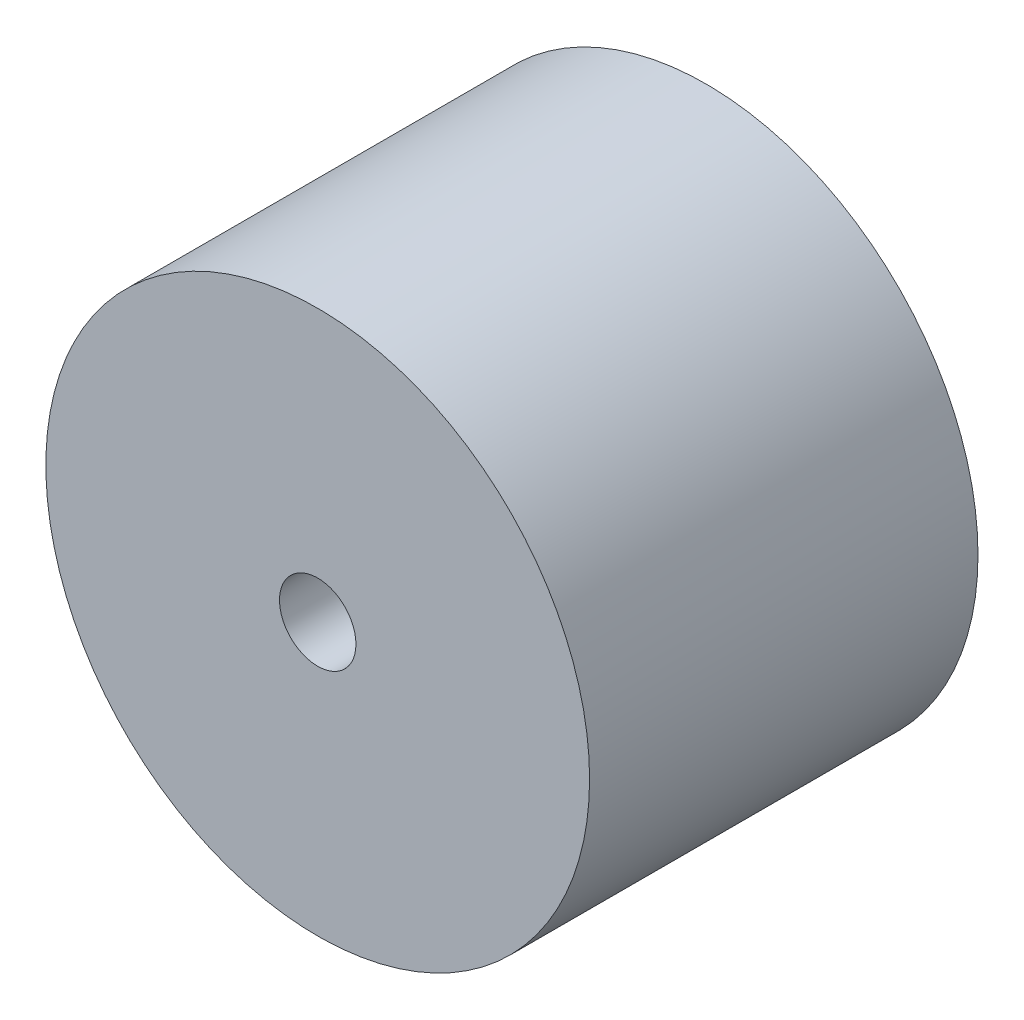
from build123d import *

# Parameters (mm, degrees)
SKETCH2_R           = 17.78
SKETCH2_R_2         = 2.5
BOSS_EXTRUDE1_DEPTH = 25.4


with BuildPart() as part:
    # Sketch2 → Boss-Extrude1 (new body)
    with BuildSketch(Plane.XY):
        Circle(SKETCH2_R)
        Circle(SKETCH2_R_2, mode=Mode.SUBTRACT)
    extrude(amount=BOSS_EXTRUDE1_DEPTH)


solid = part.part
